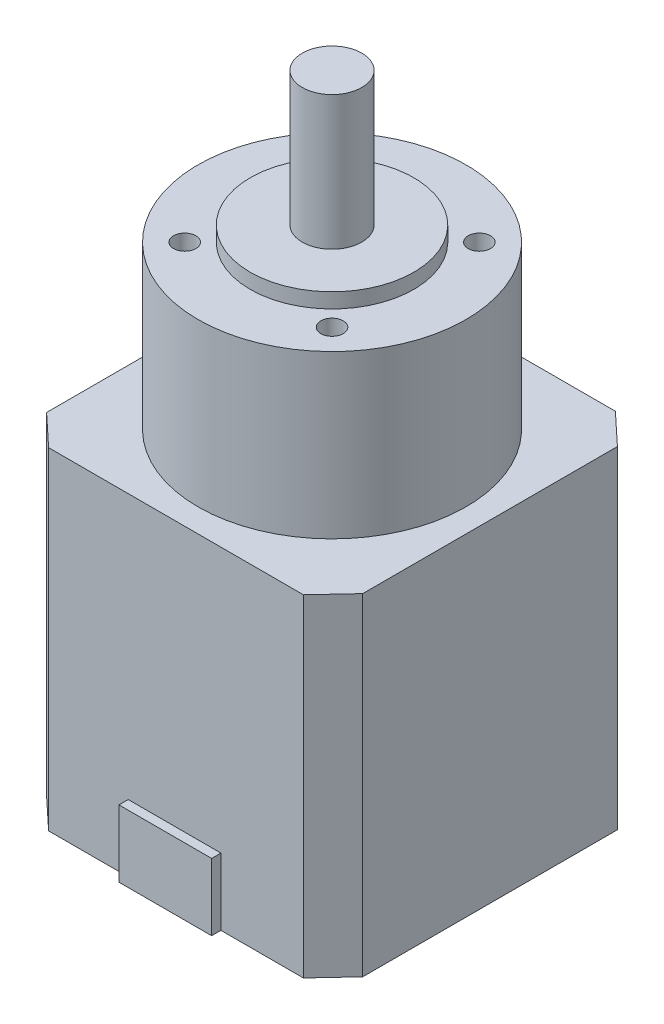
from build123d import *

# Parameters (mm, degrees)
SKETCH1_R           = 18.01
SKETCH1_R_2         = 11
SKETCH1_R_3         = 1.5
SKETCH1_R_4         = 4
BOSS_EXTRUDE1_DEPTH = 44.6
BOSS_EXTRUDE2_START = 44.6
SKETCH1_3_R         = 18.01
SKETCH1_3_R_2       = 11
SKETCH1_3_R_3       = 1.5
SKETCH1_3_R_4       = 4
BOSS_EXTRUDE2_DEPTH = 21.8
BOSS_EXTRUDE3_START = 66.4
SKETCH1_4_R         = 11
SKETCH1_4_R_2       = 4
BOSS_EXTRUDE3_DEPTH = 2
CUT_EXTRUDE1_START  = 66.4
SKETCH1_5_R         = 1.5
CUT_EXTRUDE1_DEPTH  = 4.5
BOSS_EXTRUDE4_START = 66.4
SKETCH1_6_R         = 4
BOSS_EXTRUDE4_DEPTH = 20
SKETCH1_7_W         = 12.459329624
SKETCH1_7_H         = 1.245276847
BOSS_EXTRUDE5_DEPTH = 9


with BuildPart() as part:
    # Sketch1 → Boss-Extrude1 (new body)
    with BuildSketch(Plane(origin=(0, 0, 0), x_dir=(1, 0, 0), z_dir=(0, 1, 0))):
        Polygon((-17.084609899, 21.16), (-21.16, 16.798777214), (-21.16, -17.201222786), (-16.923568895, -21.16), (-6.229664812, -21.16), (6.229664812, -21.16), (17.310192914, -21.16), (21.16, -17.040181782), (21.16, 17.193580027), (16.915390101, 21.16), align=None)
        Circle(SKETCH1_R, mode=Mode.SUBTRACT)
        Circle(SKETCH1_R)
        Circle(SKETCH1_R_2, mode=Mode.SUBTRACT)
        with Locations((-9.899494937, 9.899494937)):
            Circle(SKETCH1_R_3, mode=Mode.SUBTRACT)
        with Locations((-9.899494937, -9.899494937)):
            Circle(SKETCH1_R_3, mode=Mode.SUBTRACT)
        with Locations((9.899494937, -9.899494937)):
            Circle(SKETCH1_R_3, mode=Mode.SUBTRACT)
        with Locations((9.899494937, 9.899494937)):
            Circle(SKETCH1_R_3, mode=Mode.SUBTRACT)
        Circle(SKETCH1_R_2)
        Circle(SKETCH1_R_4, mode=Mode.SUBTRACT)
        with Locations((9.899494937, 9.899494937)):
            Circle(SKETCH1_R_3)
        with Locations((9.899494937, -9.899494937)):
            Circle(SKETCH1_R_3)
        with Locations((-9.899494937, -9.899494937)):
            Circle(SKETCH1_R_3)
        with Locations((-9.899494937, 9.899494937)):
            Circle(SKETCH1_R_3)
        Circle(SKETCH1_R_4)
    extrude(amount=BOSS_EXTRUDE1_DEPTH)

    # Sketch1_3 → Boss-Extrude2 (add)
    with BuildSketch(Plane(origin=(0, 0, 0), x_dir=(1, 0, 0), z_dir=(0, 1, 0)).offset(BOSS_EXTRUDE2_START)):
        Circle(SKETCH1_3_R)
        Circle(SKETCH1_3_R_2, mode=Mode.SUBTRACT)
        with Locations((-9.899494937, 9.899494937)):
            Circle(SKETCH1_3_R_3, mode=Mode.SUBTRACT)
        with Locations((-9.899494937, -9.899494937)):
            Circle(SKETCH1_3_R_3, mode=Mode.SUBTRACT)
        with Locations((9.899494937, -9.899494937)):
            Circle(SKETCH1_3_R_3, mode=Mode.SUBTRACT)
        with Locations((9.899494937, 9.899494937)):
            Circle(SKETCH1_3_R_3, mode=Mode.SUBTRACT)
        Circle(SKETCH1_3_R_2)
        Circle(SKETCH1_3_R_4, mode=Mode.SUBTRACT)
        with Locations((-9.899494937, -9.899494937)):
            Circle(SKETCH1_3_R_3)
        with Locations((9.899494937, -9.899494937)):
            Circle(SKETCH1_3_R_3)
        with Locations((9.899494937, 9.899494937)):
            Circle(SKETCH1_3_R_3)
        with Locations((-9.899494937, 9.899494937)):
            Circle(SKETCH1_3_R_3)
        Circle(SKETCH1_3_R_4)
    extrude(amount=BOSS_EXTRUDE2_DEPTH)

    # Sketch1_4 → Boss-Extrude3 (add)
    with BuildSketch(Plane(origin=(0, 0, 0), x_dir=(1, 0, 0), z_dir=(0, 1, 0)).offset(BOSS_EXTRUDE3_START)):
        Circle(SKETCH1_4_R)
        Circle(SKETCH1_4_R_2, mode=Mode.SUBTRACT)
        Circle(SKETCH1_4_R_2)
    extrude(amount=BOSS_EXTRUDE3_DEPTH)

    # Sketch1_5 → Cut-Extrude1 (cut)
    with BuildSketch(Plane(origin=(0, 0, 0), x_dir=(1, 0, 0), z_dir=(0, 1, 0)).offset(CUT_EXTRUDE1_START)):
        with Locations((9.899494937, -9.899494937)):
            Circle(SKETCH1_5_R)
        with Locations((9.899494937, 9.899494937)):
            Circle(SKETCH1_5_R)
        with Locations((-9.899494937, 9.899494937)):
            Circle(SKETCH1_5_R)
        with Locations((-9.899494937, -9.899494937)):
            Circle(SKETCH1_5_R)
    extrude(amount=-CUT_EXTRUDE1_DEPTH, mode=Mode.SUBTRACT)

    # Sketch1_6 → Boss-Extrude4 (add)
    with BuildSketch(Plane(origin=(0, 0, 0), x_dir=(1, 0, 0), z_dir=(0, 1, 0)).offset(BOSS_EXTRUDE4_START)):
        Circle(SKETCH1_6_R)
    extrude(amount=BOSS_EXTRUDE4_DEPTH)

    # Sketch1_7 → Boss-Extrude5 (add)
    with BuildSketch(Plane(origin=(0, 0, 0), x_dir=(1, 0, 0), z_dir=(0, 1, 0))):
        with Locations((0, -21.782638423)):
            Rectangle(SKETCH1_7_W, SKETCH1_7_H)
    extrude(amount=BOSS_EXTRUDE5_DEPTH)


solid = part.part
